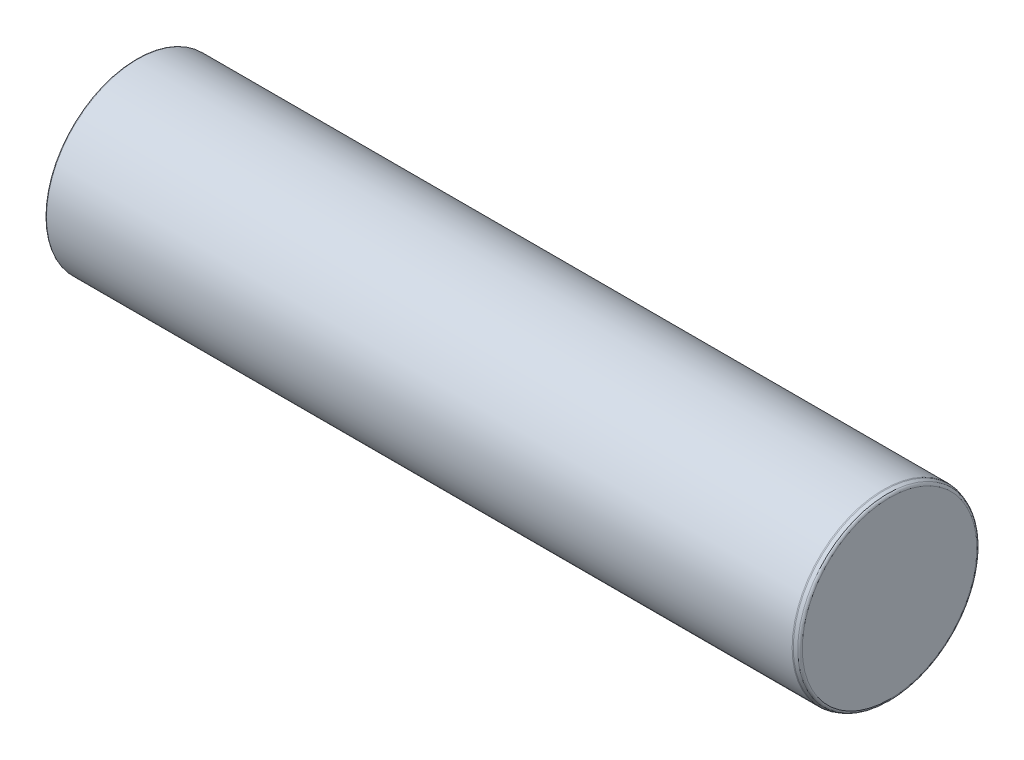
from build123d import *


with BuildPart() as part:
    # Sketch1 → Base-Revolve (revolve)
    with BuildSketch(Plane.XY):
        with BuildLine():
            Line((134.323673019, 32.5), (-9.4019e-05, 32.5))
            Line((-9.4019e-05, 32.5), (-131.1, 32.5))
            ThreePointArc((-131.1, 32.5), (-131.382842712, 32.382842712), (-131.5, 32.1))
            Line((-131.5, 32.1), (-131.5, 28.4))
            ThreePointArc((-131.5, 28.4), (-131.617157288, 28.117157288), (-131.9, 28))
            Line((-131.9, 28), (-132.5, 28))
            Line((-132.5, 28), (-132.5, 25.230940108))
            ThreePointArc((-132.5, 25.230940108), (-132.553589838, 25.030940108), (-132.7, 24.884529946))
            Line((-132.7, 24.884529946), (-136.3, 22.806068977))
            ThreePointArc((-136.3, 22.806068977), (-136.446410162, 22.659658816), (-136.5, 22.459658816))
            Line((-136.5, 22.459658816), (-136.5, 5.1))
            Line((-136.5, 5.1), (-116.5, 5.1))
            Line((-116.5, 5.1), (-113.555513627, 0))
            Line((-113.555513627, 0), (136.5, 0))
            Line((136.5, 0), (136.5, 31.071851993))
            ThreePointArc((136.5, 31.071851993), (136.319152044, 31.64542843), (135.842020143, 32.011544614))
            Line((135.842020143, 32.011544614), (134.665693163, 32.439692621))
            ThreePointArc((134.665693163, 32.439692621), (134.497321197, 32.484807753), (134.323673019, 32.5))
        make_face()
    revolve(axis=Axis((-136.5, 0, 0), (1, 0, 0)))


solid = part.part
